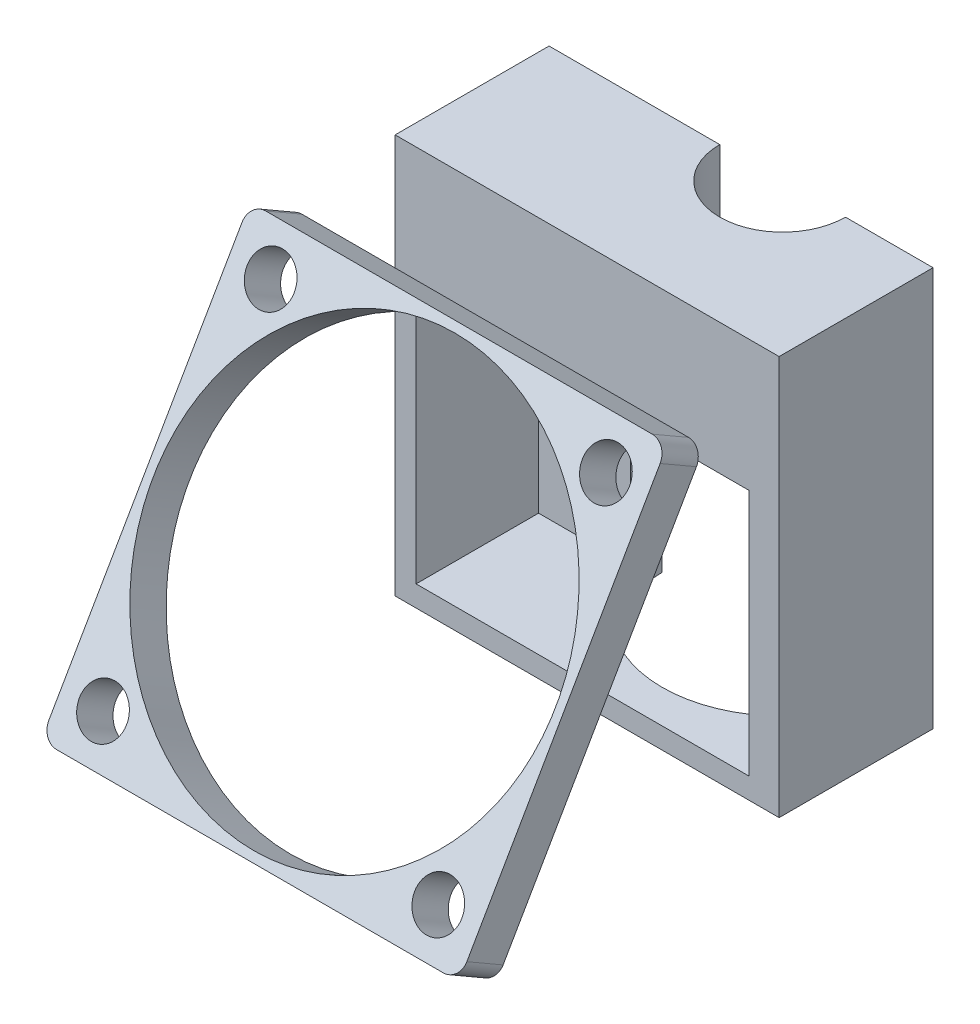
from build123d import *

# Parameters (mm, degrees)
BOSS_EXTRUDE1_DEPTH = 6
BOSS_EXTRUDE2_DEPTH = 3
BOSS_EXTRUDE3_DEPTH = 1.5
BOSS_EXTRUDE4_DEPTH = 1
BOSS_EXTRUDE5_DEPTH = 1
SKETCH6_W           = 10.792208911
SKETCH6_H           = 3
SKETCH6_W_2         = 2.857563286
BOSS_EXTRUDE6_DEPTH = 25.615903
BOSS_EXTRUDE7_START = -2
BOSS_EXTRUDE7_DEPTH = 2
BOSS_EXTRUDE8_DEPTH = 11.691588
CUT_EXTRUDE1_DEPTH  = 2
SKETCH10_R          = 19.177152658
BOSS_EXTRUDE9_DEPTH = 4


with BuildPart() as part:
    # Sketch1 → Boss-Extrude1 (new body)
    with BuildSketch(Plane(origin=(0, -168.647191902, 0), x_dir=(1, 0, 0), z_dir=(0, 1, 0))):
        with BuildLine():
            Line((-33.407184222, -166.859176326), (-25.049620936, -166.859176326))
            Line((-25.049620936, -166.859176326), (-25.049620936, -172.050763846))
            Line((-25.049620936, -172.050763846), (-25.049620936, -181.550763846))
            Line((-25.049620936, -181.550763846), (-61.699393133, -181.550763846))
            Line((-61.699393133, -181.550763846), (-61.699393133, -166.859176326))
            Line((-61.699393133, -166.859176326), (-45.407184222, -166.859176326))
            ThreePointArc((-45.407184222, -166.859176326), (-39.407184222, -172.859176326), (-33.407184222, -166.859176326))
        make_face()
    extrude(amount=-BOSS_EXTRUDE1_DEPTH)

    # Sketch2 → Boss-Extrude2 (add)
    with BuildSketch(Plane.XZ.offset(174.647191902)):
        with BuildLine():
            Line((-47.407184222, 166.859176326), (-61.699393133, 166.859176326))
            Line((-61.699393133, 166.859176326), (-61.699393133, 181.550763846))
            Line((-61.699393133, 181.550763846), (-25.049620936, 181.550763846))
            Line((-25.049620936, 181.550763846), (-25.049620936, 166.859176326))
            Line((-25.049620936, 166.859176326), (-31.407184222, 166.859176326))
            ThreePointArc((-31.407184222, 166.859176326), (-39.407184222, 174.859176326), (-47.407184222, 166.859176326))
        make_face()
    extrude(amount=BOSS_EXTRUDE2_DEPTH)

    # Sketch3 → Boss-Extrude3 (add)
    with BuildSketch(Plane.XZ.offset(177.647191902)):
        with BuildLine():
            Line((-45.407184222, 166.859176326), (-61.699393133, 166.859176326))
            Line((-61.699393133, 166.859176326), (-61.699393133, 181.550763846))
            Line((-61.699393133, 181.550763846), (-25.049620936, 181.550763846))
            Line((-25.049620936, 181.550763846), (-25.049620936, 166.859176326))
            Line((-25.049620936, 166.859176326), (-33.407184222, 166.859176326))
            ThreePointArc((-33.407184222, 166.859176326), (-39.407184222, 172.859176326), (-45.407184222, 166.859176326))
        make_face()
    extrude(amount=BOSS_EXTRUDE3_DEPTH)

    # Sketch4 → Boss-Extrude4 (add)
    with BuildSketch(Plane.XZ.offset(179.147191902)):
        with BuildLine():
            Line((-47.407184222, 166.859176326), (-61.699393133, 166.859176326))
            Line((-61.699393133, 166.859176326), (-61.699393133, 181.550763846))
            Line((-61.699393133, 181.550763846), (-25.049620936, 181.550763846))
            Line((-25.049620936, 181.550763846), (-25.049620936, 166.859176326))
            Line((-25.049620936, 166.859176326), (-31.407184222, 166.859176326))
            ThreePointArc((-31.407184222, 166.859176326), (-39.407184222, 174.859176326), (-47.407184222, 166.859176326))
        make_face()
    extrude(amount=BOSS_EXTRUDE4_DEPTH)

    # Sketch5 → Boss-Extrude5 (add)
    with BuildSketch(Plane.XZ.offset(180.147191902)):
        with BuildLine():
            Line((-45.407184222, 166.859176326), (-61.699393133, 166.859176326))
            Line((-61.699393133, 166.859176326), (-61.699393133, 181.550763846))
            Line((-61.699393133, 181.550763846), (-25.049620936, 181.550763846))
            Line((-25.049620936, 181.550763846), (-25.049620936, 166.859176326))
            Line((-25.049620936, 166.859176326), (-33.407184222, 166.859176326))
            ThreePointArc((-33.407184222, 166.859176326), (-39.407184222, 172.859176326), (-45.407184222, 166.859176326))
        make_face()
    extrude(amount=BOSS_EXTRUDE5_DEPTH)

    # Sketch6 → Boss-Extrude6 (add)
    with BuildSketch(Plane.XZ.offset(181.147191902)):
        with Locations((-56.303288678, 168.359176326)):
            Rectangle(SKETCH6_W, SKETCH6_H)
        with Locations((-26.478402579, 168.359176326)):
            Rectangle(SKETCH6_W_2, SKETCH6_H)
    extrude(amount=BOSS_EXTRUDE6_DEPTH)

    # Sketch7 → Boss-Extrude7 (add)
    with BuildSketch(Plane.XZ.offset(206.763094952).offset(BOSS_EXTRUDE7_START)):
        with BuildLine():
            Line((-53.764747509, 166.859176326), (-50.907184222, 166.859176326))
            ThreePointArc((-50.907184222, 166.859176326), (-39.407184222, 178.359176326), (-27.907184222, 166.859176326))
            Line((-27.907184222, 166.859176326), (-25.049620936, 166.859176326))
            ThreePointArc((-25.049620936, 166.859176326), (-39.407184222, 181.216739613), (-53.764747509, 166.859176326))
        make_face()
    extrude(amount=BOSS_EXTRUDE7_DEPTH)

    # Sketch8 → Boss-Extrude8 (add)
    with BuildSketch(Plane.XY.offset(181.550763846)):
        Polygon((-25.366542373, -206.763094952), (-25.049620936, -206.763094952), (-25.049620936, -181.147191902), (-27.907184222, -181.147191902), (-27.907184222, -204.763094952), (-50.907184222, -204.763094952), (-59.699393133, -204.763094952), (-59.699393133, -181.147191902), (-61.699393133, -181.147191902), (-61.699393133, -206.763094952), (-53.447826071, -206.763094952), align=None)
    extrude(amount=-BOSS_EXTRUDE8_DEPTH)

    # Sketch9 → Cut-Extrude1 (cut)
    with BuildSketch(Plane.XZ.offset(206.763094952)):
        with BuildLine():
            Line((-50.907184222, 166.859176326), (-27.907184222, 166.859176326))
            ThreePointArc((-27.907184222, 166.859176326), (-39.407184222, 178.359176326), (-50.907184222, 166.859176326))
        make_face()
    extrude(amount=-CUT_EXTRUDE1_DEPTH, mode=Mode.SUBTRACT)


with BuildPart() as body_2:
    # Sketch10 → Boss-Extrude9 (new body)
    with BuildSketch(Plane(origin=(0, 40.579403079, 70.285587874), x_dir=(-1, 0, 0), z_dir=(0, -0.5, -0.866025404))):
        with BuildLine():
            Line((26.549620936, -283.643524725), (63.449620936, -283.643524725))
            ThreePointArc((63.449620936, -283.643524725), (64.510281107, -283.204184897), (64.949620936, -282.143524725))
            Line((64.949620936, -282.143524725), (64.949620936, -245.243524725))
            ThreePointArc((64.949620936, -245.243524725), (64.510281107, -244.182864553), (63.449620936, -243.743524725))
            Line((63.449620936, -243.743524725), (26.549620936, -243.743524725))
            ThreePointArc((26.549620936, -243.743524725), (25.488960764, -244.182864553), (25.049620936, -245.243524725))
            Line((25.049620936, -245.243524725), (25.049620936, -282.143524725))
            ThreePointArc((25.049620936, -282.143524725), (25.488960764, -283.204184897), (26.549620936, -283.643524725))
        make_face()
        with Locations((44.999620936, -263.693524725)):
            Circle(SKETCH10_R, mode=Mode.SUBTRACT)
        with BuildLine():
            ThreePointArc((26.749620936, -279.693524725), (28.999620936, -281.943524725), (31.249620936, -279.693524725))
            ThreePointArc((31.249620936, -279.693524725), (28.999620936, -277.443524725), (26.749620936, -279.693524725))
        make_face(mode=Mode.SUBTRACT)
        with BuildLine():
            ThreePointArc((58.749620936, -279.693524725), (60.999620936, -281.943524725), (63.249620936, -279.693524725))
            ThreePointArc((63.249620936, -279.693524725), (60.999620936, -277.443524725), (58.749620936, -279.693524725))
        make_face(mode=Mode.SUBTRACT)
        with BuildLine():
            ThreePointArc((26.749620936, -247.693524725), (28.999620936, -249.943524725), (31.249620936, -247.693524725))
            ThreePointArc((31.249620936, -247.693524725), (28.999620936, -245.443524725), (26.749620936, -247.693524725))
        make_face(mode=Mode.SUBTRACT)
        with BuildLine():
            ThreePointArc((63.249620936, -247.693524725), (60.999620936, -245.443524725), (58.749620936, -247.693524725))
            ThreePointArc((58.749620936, -247.693524725), (60.999620936, -249.943524725), (63.249620936, -247.693524725))
        make_face(mode=Mode.SUBTRACT)
    extrude(amount=BOSS_EXTRUDE9_DEPTH)


solid = Compound([part.part, body_2.part])
